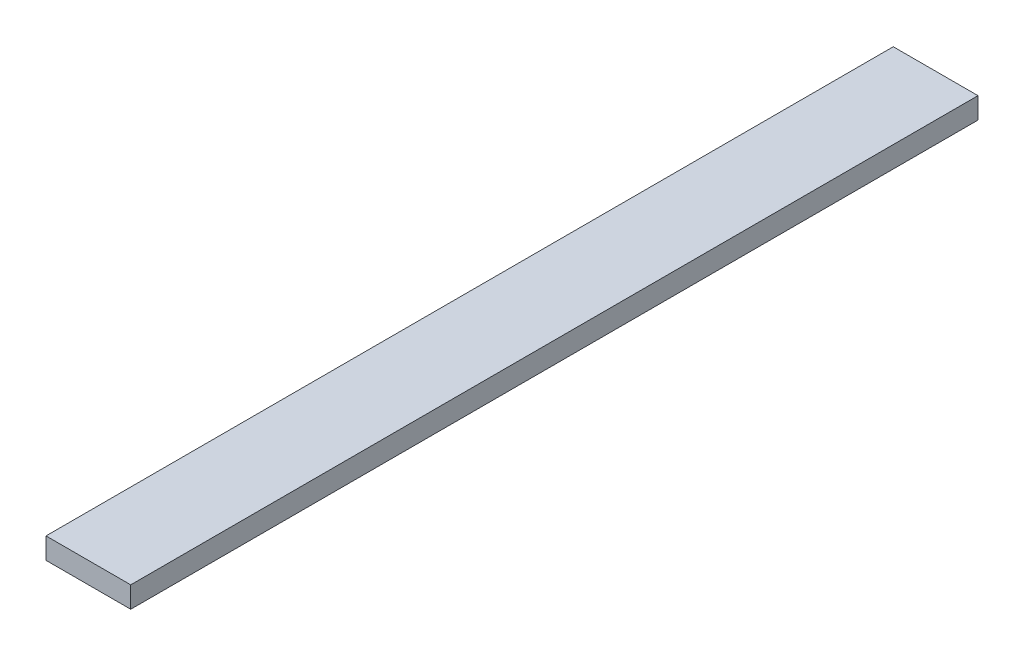
from build123d import *

# Parameters (mm, degrees)
SKETCH1_W           = 6
SKETCH1_H           = 60
BOSS_EXTRUDE1_DEPTH = 1.5


with BuildPart() as part:
    # Sketch1 → Boss-Extrude1 (new body)
    with BuildSketch(Plane(origin=(0, 0, 0), x_dir=(1, 0, 0), z_dir=(0, 1, 0))):
        Rectangle(SKETCH1_W, SKETCH1_H)
    extrude(amount=BOSS_EXTRUDE1_DEPTH)


solid = part.part
